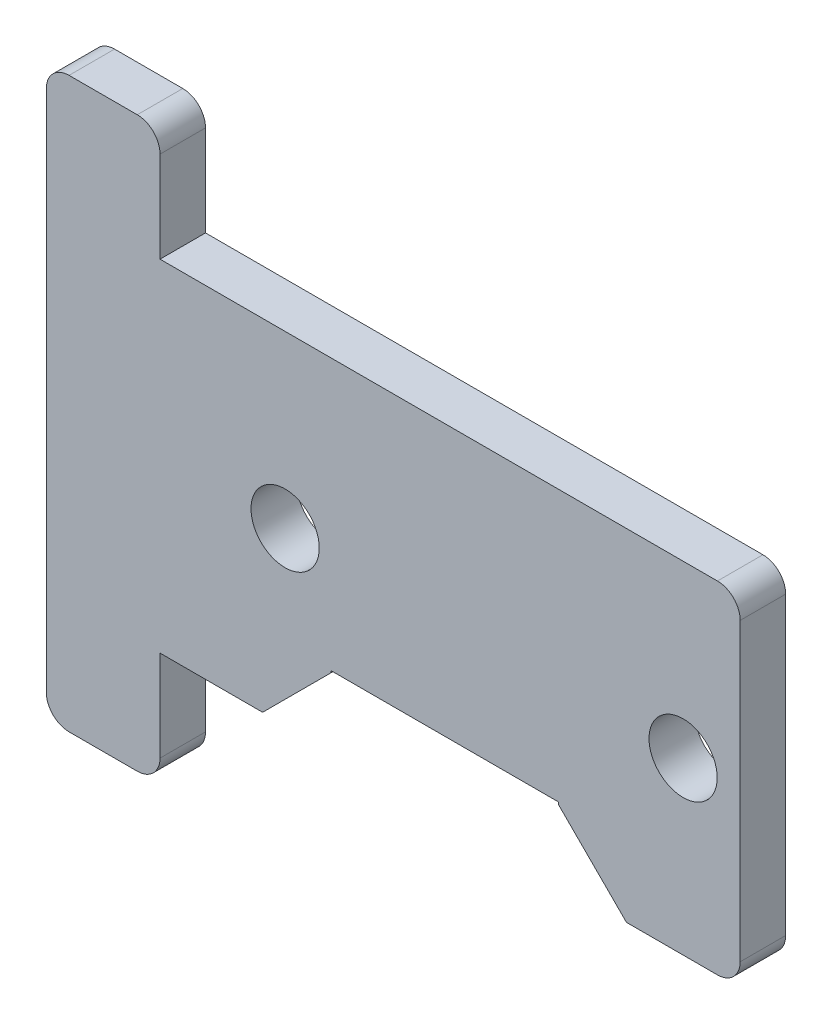
from build123d import *

# Parameters (mm, degrees)
SKETCH1_R           = 1.5
BOSS_EXTRUDE1_DEPTH = 2


with BuildPart() as part:
    # Sketch1 → Boss-Extrude1 (new body)
    with BuildSketch(Plane.XY):
        with BuildLine():
            Line((-10.646329578, -7.696708369), (-10.646329578, -11.696708369))
            ThreePointArc((-10.646329578, -11.696708369), (-10.939222796, -12.40381515), (-11.646329578, -12.696708369))
            Line((-11.646329578, -12.696708369), (-14.646329578, -12.696708369))
            ThreePointArc((-14.646329578, -12.696708369), (-15.353436359, -12.40381515), (-15.646329578, -11.696708369))
            Line((-15.646329578, -11.696708369), (-15.646329578, 11.303291631))
            ThreePointArc((-15.646329578, 11.303291631), (-15.353436359, 12.010398412), (-14.646329578, 12.303291631))
            Line((-14.646329578, 12.303291631), (-11.646329578, 12.303291631))
            ThreePointArc((-11.646329578, 12.303291631), (-10.939222796, 12.010398412), (-10.646329578, 11.303291631))
            Line((-10.646329578, 11.303291631), (-10.646329578, 7.303291631))
            Line((-10.646329578, 7.303291631), (13.863670422, 7.303291631))
            ThreePointArc((13.863670422, 7.303291631), (14.570777204, 7.010398412), (14.863670422, 6.303291631))
            Line((14.863670422, 6.303291631), (14.863670422, -6.696708369))
            ThreePointArc((14.863670422, -6.696708369), (14.570777204, -7.40381515), (13.863670422, -7.696708369))
            Line((13.863670422, -7.696708369), (9.863670422, -7.696708369))
            Line((9.863670422, -7.696708369), (6.863670422, -4.696708369))
            Line((6.863670422, -4.696708369), (6.863670422, -4.605403467))
            Line((6.863670422, -4.605403467), (-3.136329578, -4.605403467))
            Line((-3.136329578, -4.605403467), (-3.136329578, -4.696708369))
            Line((-3.136329578, -4.696708369), (-6.136329578, -7.696708369))
            Line((-6.136329578, -7.696708369), (-10.646329578, -7.696708369))
        make_face()
        with Locations((12.353670422, -0.196708369)):
            Circle(SKETCH1_R, mode=Mode.SUBTRACT)
        with Locations((-5.146329578, -0.196708369)):
            Circle(SKETCH1_R, mode=Mode.SUBTRACT)
    extrude(amount=BOSS_EXTRUDE1_DEPTH)


solid = part.part
